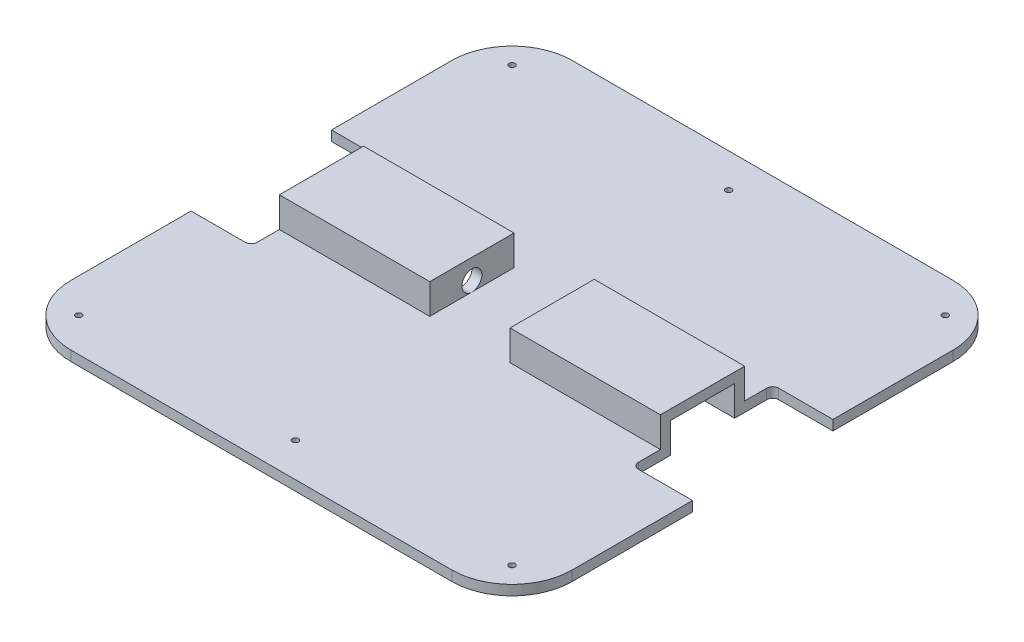
from build123d import *

# Parameters (mm, degrees)
BOSS_EXTRUDE1_DEPTH = 125
SKETCH4_W           = 32
SKETCH4_H           = 15
CUT_EXTRUDE1_DEPTH  = 100
SKETCH5_W           = 32
SKETCH5_H           = 15
CUT_EXTRUDE2_DEPTH  = 100
CUT_EXTRUDE3_REACH  = 22
SKETCH6_W           = 30
SKETCH6_H           = 70
CUT_EXTRUDE4_DEPTH  = 15
SKETCH8_R           = 4.5
CUT_EXTRUDE5_DEPTH  = 15
SKETCH9_R           = 5
CUT_EXTRUDE6_DEPTH  = 15
FILLET1_R           = 3
FILLET2_R           = 30
CUT_EXTRUDE7_REACH  = 7
SKETCH11_R          = 1.5
SKETCH11_R_2        = 1.502187573


with BuildPart() as part:
    # Sketch3 → Boss-Extrude1 (new body, symmetric)
    with BuildSketch(Plane(origin=(0, 0, 0), x_dir=(0, 0, -1), z_dir=(1, 0, 0))):
        Polygon((0, 0), (0, 5), (104, 5), (104, 20), (146, 20), (146, 5), (250, 5), (250, 0), align=None)
    extrude(amount=BOSS_EXTRUDE1_DEPTH, both=True)

    # Sketch4 → Cut-Extrude1 (cut)
    with BuildSketch(Plane(origin=(125, 0, 0), x_dir=(0, 0, -1), z_dir=(1, 0, 0))):
        with Locations((125, 7.5)):
            Rectangle(SKETCH4_W, SKETCH4_H)
    extrude(amount=-CUT_EXTRUDE1_DEPTH, mode=Mode.SUBTRACT)

    # Sketch5 → Cut-Extrude2 (cut)
    with BuildSketch(Plane.ZY.offset(125)):
        with Locations((-125, 7.5)):
            Rectangle(SKETCH5_W, SKETCH5_H)
    extrude(amount=-CUT_EXTRUDE2_DEPTH, mode=Mode.SUBTRACT)

    # Sketch6 → Cut-Extrude3 (cut, up to next)
    with BuildSketch(Plane(origin=(0, 20, 0), x_dir=(1, 0, 0), z_dir=(0, 1, 0)), mode=Mode.PRIVATE) as cut_extrude3_sk1:
        with Locations((-110, 125)):
            Rectangle(SKETCH6_W, SKETCH6_H)
    cut_extrude3_tool1 = extrude(cut_extrude3_sk1.sketch, amount=-CUT_EXTRUDE3_REACH, mode=Mode.PRIVATE) & part.part
    add(cut_extrude3_tool1.solids().sort_by_distance((-110, 20, -125))[0], mode=Mode.SUBTRACT)
    # Sketch6 → Cut-Extrude3 (cut, up to next)
    with BuildSketch(Plane(origin=(0, 20, 0), x_dir=(1, 0, 0), z_dir=(0, 1, 0)), mode=Mode.PRIVATE) as cut_extrude3_sk2:
        with Locations((110, 125)):
            Rectangle(SKETCH6_W, SKETCH6_H)
    cut_extrude3_tool2 = extrude(cut_extrude3_sk2.sketch, amount=-CUT_EXTRUDE3_REACH, mode=Mode.PRIVATE) & part.part
    add(cut_extrude3_tool2.solids().sort_by_distance((110, 20, -125))[0], mode=Mode.SUBTRACT)

    # Sketch7 → Cut-Extrude4 (cut)
    with BuildSketch(Plane(origin=(0, 20, 0), x_dir=(1, 0, 0), z_dir=(0, 1, 0))):
        Polygon((0, 146), (-20, 146), (-20, 104), (0, 104), (20, 104), (20, 146), align=None)
    extrude(amount=-CUT_EXTRUDE4_DEPTH, mode=Mode.SUBTRACT)

    # Sketch8 → Cut-Extrude5 (cut)
    with BuildSketch(Plane.ZY.offset(-20)):
        with Locations((-125, 10)):
            Circle(SKETCH8_R)
    extrude(amount=-CUT_EXTRUDE5_DEPTH, mode=Mode.SUBTRACT)

    # Sketch9 → Cut-Extrude6 (cut)
    with BuildSketch(Plane(origin=(-20, 0, 0), x_dir=(0, 0, -1), z_dir=(1, 0, 0))):
        with Locations((125, 10)):
            Circle(SKETCH9_R)
    extrude(amount=-CUT_EXTRUDE6_DEPTH, mode=Mode.SUBTRACT)

    # Fillet1
    fillet1_edges = [part.edges().sort_by_distance(p)[0] for p in [
        (-95, 2.5, -90),
        (-95, 2.5, -160),
        (95, 2.5, -160),
        (95, 2.5, -90),
    ]]
    fillet(fillet1_edges, radius=FILLET1_R)

    # Fillet2
    fillet2_edges = [part.edges().sort_by_distance(p)[0] for p in [
        (-125, 2.5, -250),
        (125, 2.5, 0),
        (-125, 2.5, 0),
        (125, 2.5, -250),
    ]]
    fillet(fillet2_edges, radius=FILLET2_R)

    # Sketch11 → Cut-Extrude7 (cut, up to next)
    with BuildSketch(Plane(origin=(0, 5, 0), x_dir=(1, 0, 0), z_dir=(0, 1, 0)), mode=Mode.PRIVATE) as cut_extrude7_sk1:
        with Locations((-108, 233)):
            Circle(SKETCH11_R)
    cut_extrude7_tool1 = extrude(cut_extrude7_sk1.sketch, amount=-CUT_EXTRUDE7_REACH, mode=Mode.PRIVATE) & part.part
    add(cut_extrude7_tool1.solids().sort_by_distance((-108, 5, -233))[0], mode=Mode.SUBTRACT)
    # Sketch11 → Cut-Extrude7 (cut, up to next)
    with BuildSketch(Plane(origin=(0, 5, 0), x_dir=(1, 0, 0), z_dir=(0, 1, 0)), mode=Mode.PRIVATE) as cut_extrude7_sk2:
        with Locations((108, 233)):
            Circle(SKETCH11_R)
    cut_extrude7_tool2 = extrude(cut_extrude7_sk2.sketch, amount=-CUT_EXTRUDE7_REACH, mode=Mode.PRIVATE) & part.part
    add(cut_extrude7_tool2.solids().sort_by_distance((108, 5, -233))[0], mode=Mode.SUBTRACT)
    # Sketch11 → Cut-Extrude7 (cut, up to next)
    with BuildSketch(Plane(origin=(0, 5, 0), x_dir=(1, 0, 0), z_dir=(0, 1, 0)), mode=Mode.PRIVATE) as cut_extrude7_sk3:
        with Locations((108, 17)):
            Circle(SKETCH11_R)
    cut_extrude7_tool3 = extrude(cut_extrude7_sk3.sketch, amount=-CUT_EXTRUDE7_REACH, mode=Mode.PRIVATE) & part.part
    add(cut_extrude7_tool3.solids().sort_by_distance((108, 5, -17))[0], mode=Mode.SUBTRACT)
    # Sketch11 → Cut-Extrude7 (cut, up to next)
    with BuildSketch(Plane(origin=(0, 5, 0), x_dir=(1, 0, 0), z_dir=(0, 1, 0)), mode=Mode.PRIVATE) as cut_extrude7_sk4:
        with Locations((-108, 17)):
            Circle(SKETCH11_R)
    cut_extrude7_tool4 = extrude(cut_extrude7_sk4.sketch, amount=-CUT_EXTRUDE7_REACH, mode=Mode.PRIVATE) & part.part
    add(cut_extrude7_tool4.solids().sort_by_distance((-108, 5, -17))[0], mode=Mode.SUBTRACT)
    # Sketch11 → Cut-Extrude7 (cut, up to next)
    with BuildSketch(Plane(origin=(0, 5, 0), x_dir=(1, 0, 0), z_dir=(0, 1, 0)), mode=Mode.PRIVATE) as cut_extrude7_sk5:
        with Locations((0, 17)):
            Circle(SKETCH11_R)
    cut_extrude7_tool5 = extrude(cut_extrude7_sk5.sketch, amount=-CUT_EXTRUDE7_REACH, mode=Mode.PRIVATE) & part.part
    add(cut_extrude7_tool5.solids().sort_by_distance((0, 5, -17))[0], mode=Mode.SUBTRACT)
    # Sketch11 → Cut-Extrude7 (cut, up to next)
    with BuildSketch(Plane(origin=(0, 5, 0), x_dir=(1, 0, 0), z_dir=(0, 1, 0)), mode=Mode.PRIVATE) as cut_extrude7_sk6:
        with Locations((0, 233)):
            Circle(SKETCH11_R_2)
    cut_extrude7_tool6 = extrude(cut_extrude7_sk6.sketch, amount=-CUT_EXTRUDE7_REACH, mode=Mode.PRIVATE) & part.part
    add(cut_extrude7_tool6.solids().sort_by_distance((0, 5, -233))[0], mode=Mode.SUBTRACT)


solid = part.part
